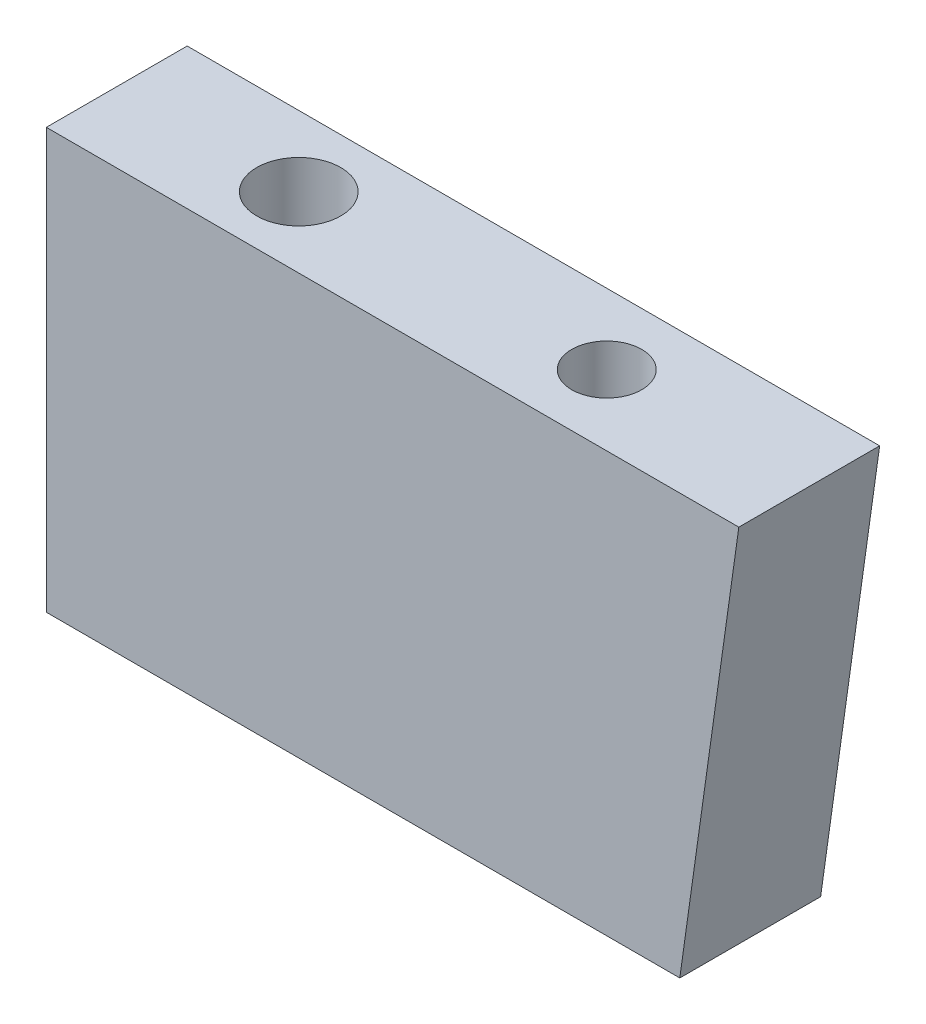
from build123d import *

# Parameters (mm, degrees)
EXTRUDE1_DEPTH                 = 2.515
M3X0_5_TAPPED_HOLE2_AT_2_COUNT = 2
M3X0_5_TAPPED_HOLE2_AT_2_PITCH = 37
M3X0_5_TAPPED_HOLE2_AT_3_COUNT = 2
M3X0_5_TAPPED_HOLE2_AT_3_PITCH = 74
M3X0_5_TAPPED_HOLE2_AT_4_COUNT = 2
M3X0_5_TAPPED_HOLE2_AT_4_PITCH = 111
M3X0_5_TAPPED_HOLE2_AT_5_COUNT = 2
M3X0_5_TAPPED_HOLE2_AT_5_PITCH = 148
CUT_EXTRUDE1_DEPTH             = 6.03
M3X0_5_TAPPED_HOLE1_D          = 3
M3X0_5_TAPPED_HOLE1_DEPTH      = 7.5
M3X0_5_TAPPED_HOLE1_TIP        = 0.901290929
F_2_5_2_5_DIAMETER_HOLE1_D     = 2.5
F_2_5_2_5_DIAMETER_HOLE1_DEPTH = 6
F_2_5_2_5_DIAMETER_HOLE1_TIP   = 0.751075774


with BuildPart() as part:
    # Sketch1 → Extrude1 (new body, symmetric)
    with BuildSketch(Plane.XY):
        with BuildLine():
            Line((29.232493618, 208), (4.5, 208))
            Line((4.5, 208), (4.5, 37.873672337))
            ThreePointArc((4.5, 37.873672337), (38.14007153, 0), (4.5, -37.873672337))
            Line((4.5, -37.873672337), (4.5, -208))
            Line((4.5, -208), (29.232493618, -208))
            Line((29.232493618, -208), (12, -85.384436669))
            Line((12, -85.384436669), (12, -60))
            ThreePointArc((12, -60), (14.850141486, -49.710084891), (22.588235294, -42.352941176))
            ThreePointArc((22.588235294, -42.352941176), (48, 0), (22.588235294, 42.352941176))
            ThreePointArc((22.588235294, 42.352941176), (14.850141486, 49.710084891), (12, 60))
            Line((12, 60), (12, 85.384436669))
            Line((12, 85.384436669), (29.232493618, 208))
        make_face()
    extrude(amount=EXTRUDE1_DEPTH, both=True)

    # Sketch32 → M3x0.5 Tapped Hole2 (revolve, cut)
    with BuildSketch(Plane(origin=(4.5, 198, 0), x_dir=(0, 0, 1), z_dir=(0, 1, 0))):
        Polygon((0, 0), (0, 8.401290929), (1.5, 7.5), (1.5, 0), align=None)
    m3x0_5_tapped_hole2 = revolve(axis=Axis((-1.85, 198, 0), (1, 0, 0)), mode=Mode.SUBTRACT)

    # M3x0.5 Tapped Hole2 at 2: M3x0.5 Tapped Hole2 ×2
    with Locations(*[(0, -i * M3X0_5_TAPPED_HOLE2_AT_2_PITCH, 0) for i in range(1, M3X0_5_TAPPED_HOLE2_AT_2_COUNT)]):
        add(m3x0_5_tapped_hole2, mode=Mode.SUBTRACT)

    # M3x0.5 Tapped Hole2 at 3: M3x0.5 Tapped Hole2 ×2
    with Locations(*[(0, -i * M3X0_5_TAPPED_HOLE2_AT_3_PITCH, 0) for i in range(1, M3X0_5_TAPPED_HOLE2_AT_3_COUNT)]):
        add(m3x0_5_tapped_hole2, mode=Mode.SUBTRACT)

    # M3x0.5 Tapped Hole2 at 4: M3x0.5 Tapped Hole2 ×2
    with Locations(*[(0, -i * M3X0_5_TAPPED_HOLE2_AT_4_PITCH, 0) for i in range(1, M3X0_5_TAPPED_HOLE2_AT_4_COUNT)]):
        add(m3x0_5_tapped_hole2, mode=Mode.SUBTRACT)

    # M3x0.5 Tapped Hole2 at 5: M3x0.5 Tapped Hole2 ×2
    with Locations(*[(0, -i * M3X0_5_TAPPED_HOLE2_AT_5_PITCH, 0) for i in range(1, M3X0_5_TAPPED_HOLE2_AT_5_COUNT)]):
        add(m3x0_5_tapped_hole2, mode=Mode.SUBTRACT)

    # Mirror2: M3x0.5 Tapped Hole2 across plane
    add(m3x0_5_tapped_hole2.mirror(Plane.ZX), mode=Mode.SUBTRACT)

    # Mirror2 copy 1 sketch → Mirror2 copy 1 (revolve, cut)
    with BuildSketch(Plane(origin=(4.5, -161, 0), x_dir=(0, 0, 1), z_dir=(0, -1, 0))):
        Polygon((0, 0), (0, -8.401290929), (1.5, -7.5), (1.5, 0), align=None)
    revolve(axis=Axis((-1.85, -161, 0), (-1, 0, 0)), mode=Mode.SUBTRACT)

    # Mirror2 copy 2 sketch → Mirror2 copy 2 (revolve, cut)
    with BuildSketch(Plane(origin=(4.5, -124, 0), x_dir=(0, 0, 1), z_dir=(0, -1, 0))):
        Polygon((0, 0), (0, -8.401290929), (1.5, -7.5), (1.5, 0), align=None)
    revolve(axis=Axis((-1.85, -124, 0), (-1, 0, 0)), mode=Mode.SUBTRACT)

    # Mirror2 copy 3 sketch → Mirror2 copy 3 (revolve, cut)
    with BuildSketch(Plane(origin=(4.5, -87, 0), x_dir=(0, 0, 1), z_dir=(0, -1, 0))):
        Polygon((0, 0), (0, -8.401290929), (1.5, -7.5), (1.5, 0), align=None)
    revolve(axis=Axis((-1.85, -87, 0), (-1, 0, 0)), mode=Mode.SUBTRACT)

    # Mirror2 copy 4 sketch → Mirror2 copy 4 (revolve, cut)
    with BuildSketch(Plane(origin=(4.5, -50, 0), x_dir=(0, 0, 1), z_dir=(0, -1, 0))):
        Polygon((0, 0), (0, -8.401290929), (1.5, -7.5), (1.5, 0), align=None)
    revolve(axis=Axis((-1.85, -50, 0), (-1, 0, 0)), mode=Mode.SUBTRACT)

    # Sketch36 → Cut-Extrude1 (cut, through all)
    with BuildSketch(Plane.XY.offset(2.515)):
        with BuildLine():
            Line((4.5, 193), (27.124381098, 193))
            Line((27.124381098, 193), (12, 85.384436669))
            Line((12, 85.384436669), (12, 60))
            ThreePointArc((12, 60), (14.850141486, 49.710084891), (22.588235294, 42.352941176))
            ThreePointArc((22.588235294, 42.352941176), (48, 0), (22.588235294, -42.352941176))
            ThreePointArc((22.588235294, -42.352941176), (14.850141486, -49.710084891), (12, -60))
            Line((12, -60), (12, -85.384436669))
            Line((12, -85.384436669), (29.232493618, -208))
            Line((29.232493618, -208), (4.5, -208))
            Line((4.5, -208), (4.5, -37.873672337))
            ThreePointArc((4.5, -37.873672337), (38.14007153, 0), (4.5, 37.873672337))
            Line((4.5, 37.873672337), (4.5, 193))
        make_face()
    extrude(amount=-CUT_EXTRUDE1_DEPTH, mode=Mode.SUBTRACT)

    # M3x0.5 Tapped Hole1
    with Locations(Plane(origin=(0, 208, 0), x_dir=(-1, 0, 0), z_dir=(0, 1, 0))):
        with Locations((-11, 0)):
            Hole(M3X0_5_TAPPED_HOLE1_D / 2, depth=M3X0_5_TAPPED_HOLE1_DEPTH)
            with Locations((0, 0, -(M3X0_5_TAPPED_HOLE1_DEPTH + M3X0_5_TAPPED_HOLE1_TIP / 2))):  # 118° drill point
                Cone(0, M3X0_5_TAPPED_HOLE1_D / 2, M3X0_5_TAPPED_HOLE1_TIP, mode=Mode.SUBTRACT)

    # 2.5 _2.5_ Diameter Hole1
    with Locations(Plane(origin=(0, 208, 0), x_dir=(-1, 0, 0), z_dir=(0, 1, 0))):
        with Locations((-22, 0)):
            Hole(F_2_5_2_5_DIAMETER_HOLE1_D / 2, depth=F_2_5_2_5_DIAMETER_HOLE1_DEPTH)
            with Locations((0, 0, -(F_2_5_2_5_DIAMETER_HOLE1_DEPTH + F_2_5_2_5_DIAMETER_HOLE1_TIP / 2))):  # 118° drill point
                Cone(0, F_2_5_2_5_DIAMETER_HOLE1_D / 2, F_2_5_2_5_DIAMETER_HOLE1_TIP, mode=Mode.SUBTRACT)


solid = part.part
